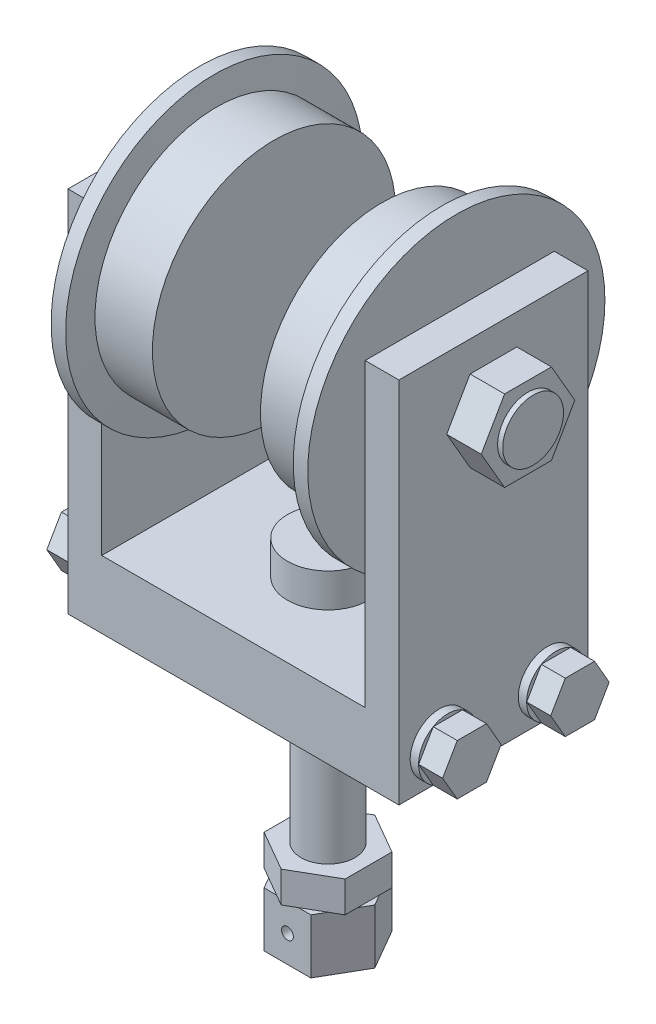
from build123d import *

# Parameters (mm, degrees)
YOKE_CROSS_SECTION_W           = 88.9
YOKE_CROSS_SECTION_H           = 31.75
YOKE_DEPTH                     = 61.9125
SIDEPLATE_PROFILE_W            = 88.9
SIDEPLATE_PROFILE_H            = 173.0375
SIDEPLATE_DEPTH                = 15.875
WHEEL_PIN_NUT_DEPTH            = 16.2306
WHEEL_PIN_PROJECTION_PROFILE_R = 14.2875
WHEEL_PIN_PROJECTION_DEPTH     = 2.413
LOCKNUTS_PROFILE_R             = 13.7541
LOCKNUTS_DEPTH                 = 3.9624
SCREWS_DEPTH                   = 11.2776
PROFILE_R                      = 19.05
KING_BOLT_HEAD_DEPTH           = 15.875
DIA_R                          = 12.7
KING_BOLT_DEPTH                = 76.2
KING_BOLT_JAM_NUT_DEPTH        = 14.605
KING_BOLT_NUT_DEPTH            = 25.7048
SKETCH5_R                      = 12.7
EXTENDED_KING_BOLT_DEPTH       = 6.35
CHAMFER1_SIZE                  = 2.38125
COTTER_PIN_HOLE_REACH          = 90.9
SKETCH8_R                      = 2.7686


with BuildPart() as part:
    # YOKE CROSS SECTION → YOKE (new body)
    with BuildSketch(Plane(origin=(0, 0, 0), x_dir=(0, 0, -1), z_dir=(1, 0, 0))):
        with Locations((0, 15.875)):
            Rectangle(YOKE_CROSS_SECTION_W, YOKE_CROSS_SECTION_H)
    extrude(amount=YOKE_DEPTH)

    # SIDEPLATE PROFILE → SIDEPLATE (add)
    with BuildSketch(Plane(origin=(61.9125, 0, 0), x_dir=(0, 0, -1), z_dir=(1, 0, 0))):
        with Locations((0, 86.51875)):
            Rectangle(SIDEPLATE_PROFILE_W, SIDEPLATE_PROFILE_H)
    extrude(amount=SIDEPLATE_DEPTH)

    # WHEEL PIN NUT PROFILE → WHEEL PIN NUT (add)
    with BuildSketch(Plane(origin=(77.7875, 0, 0), x_dir=(0, 0, -1), z_dir=(1, 0, 0))):
        Polygon((21.997045256, 139.7), (10.998522628, 158.75), (-10.998522628, 158.75), (-21.997045256, 139.7), (-10.998522628, 120.65), (10.998522628, 120.65), align=None)
    extrude(amount=WHEEL_PIN_NUT_DEPTH)

    # WHEEL PIN PROJECTION PROFILE → WHEEL PIN PROJECTION (add)
    with BuildSketch(Plane(origin=(94.0181, 0, 0), x_dir=(0, 0, -1), z_dir=(1, 0, 0))):
        with Locations((0, 139.7)):
            Circle(WHEEL_PIN_PROJECTION_PROFILE_R)
    extrude(amount=WHEEL_PIN_PROJECTION_DEPTH)

    # LOCKNUTS PROFILE → LOCKNUTS (add)
    with BuildSketch(Plane(origin=(77.7875, 0, 0), x_dir=(0, 0, -1), z_dir=(1, 0, 0))):
        with Locations((-25.4, 15.875)):
            Circle(LOCKNUTS_PROFILE_R)
    locknuts = extrude(amount=LOCKNUTS_DEPTH)

    # SCREWS PROFILE → SCREWS (add)
    with BuildSketch(Plane(origin=(81.7499, 0, 0), x_dir=(0, 0, -1), z_dir=(1, 0, 0))):
        Polygon((-11.651846715, 15.875), (-18.525923357, 27.78125), (-32.274076643, 27.78125), (-39.148153285, 15.875), (-32.274076643, 3.96875), (-18.525923357, 3.96875), align=None)
    screws = extrude(amount=SCREWS_DEPTH)

    # PROFILE → KING BOLT HEAD (add)
    with BuildSketch(Plane(origin=(0, 31.75, 0), x_dir=(-1, 0, 0), z_dir=(0, 1, 0))):
        with Locations(Location((0, 0, 0), (0, 0, 90))):  # turned: the seam where the file's is
            Circle(PROFILE_R)
    extrude(amount=KING_BOLT_HEAD_DEPTH)

    # Mirror1: LOCKNUTS, SCREWS across plane
    add(locknuts.mirror(Plane.XY))
    add(screws.mirror(Plane.XY))

    # Mirror5: part across plane


with BuildPart() as part_1:
    add(part.part)
    add(part.part.mirror(Plane(origin=(0, 0, 0), x_dir=(0, 0, 1), z_dir=(1, 0, 0))))

    # DIA. → KING BOLT (add)
    with BuildSketch(Plane.XZ):
        with Locations(Location((0, 0, 0), (0, 0, 90))):  # turned: the seam where the file's is
            Circle(DIA_R)
    extrude(amount=KING_BOLT_DEPTH)

    # KING BOLT JAN NUT PROFILE → KING BOLT JAM NUT (add)
    with BuildSketch(Plane.XZ.offset(76.2)):
        Polygon((0, -21.997045256), (19.05, -10.998522628), (19.05, 10.998522628), (0, 21.997045256), (-19.05, 10.998522628), (-19.05, -10.998522628), align=None)
    extrude(amount=KING_BOLT_JAM_NUT_DEPTH)

    # KING BOLT NUT PROFILE → KING BOLT NUT (add)
    with BuildSketch(Plane.XZ.offset(90.805)):
        Polygon((21.997045256, 0), (10.998522628, 19.05), (-10.998522628, 19.05), (-21.997045256, 0), (-10.998522628, -19.05), (10.998522628, -19.05), align=None)
    extrude(amount=KING_BOLT_NUT_DEPTH)

    # Sketch5 → EXTENDED KING BOLT (add)
    with BuildSketch(Plane.XZ.offset(116.5098)):
        with Locations(Location((0, 0, 0), (0, 0, 90))):  # turned: the seam where the file's is
            Circle(SKETCH5_R)
    extrude(amount=EXTENDED_KING_BOLT_DEPTH)

    # Chamfer1
    chamfer1_edges = [part_1.edges().sort_by_distance(p)[0] for p in [
        (0, -122.8598, -12.7),
    ]]
    chamfer(chamfer1_edges, length=CHAMFER1_SIZE)

    # Sketch7 → WHEEL (revolve)
    with BuildSketch(Plane.XY, mode=Mode.PRIVATE) as wheel_sk:
        Polygon((60.325, 155.575), (60.325, 209.55), (53.498606027, 209.55), (52.3875, 196.85), (25.4, 196.85), (25.4, 139.7), (61.9125, 139.7), (61.9125, 155.575), align=None)
    wheel = revolve(wheel_sk.sketch.rotate(Axis((61.9125, 139.7, 0), (-1, 0, 0)), 90), axis=Axis((61.9125, 139.7, 0), (-1, 0, 0)))  # turned: the seam where the file's is

    # Mirror6: WHEEL across plane
    add(wheel.mirror(Plane(origin=(0, 0, 0), x_dir=(0, 0, 1), z_dir=(1, 0, 0))))

    # Sketch8 → COTTER PIN HOLE (cut, up to next)
    with BuildSketch(Plane.XY.offset(19.05), mode=Mode.PRIVATE) as cotter_pin_hole_sk1:
        with Locations((0, -103.8098)):
            Circle(SKETCH8_R)
    cotter_pin_hole_tool1 = extrude(cotter_pin_hole_sk1.sketch, amount=-COTTER_PIN_HOLE_REACH, mode=Mode.PRIVATE) & part_1.part
    add(cotter_pin_hole_tool1.solids().sort_by_distance((0, -103.8098, 19.05))[0], mode=Mode.SUBTRACT)


solid = part_1.part
